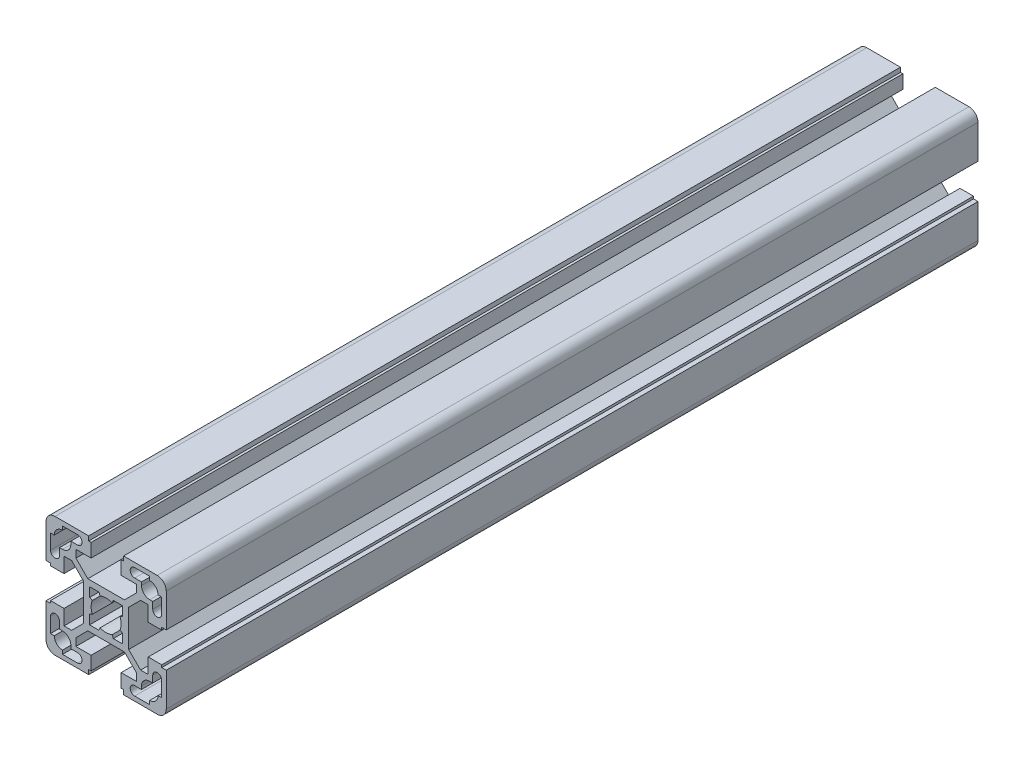
from build123d import *

# Parameters (mm, degrees)
EXTRUDE1_DEPTH = 270


with BuildPart() as part:
    # Sketch1 → Extrude1 (new body)
    with BuildSketch(Plane.XY):
        with BuildLine():
            Line((5.8, -20), (17, -20))
            ThreePointArc((17, -20), (19.121320344, -19.121320344), (20, -17))
            Line((20, -17), (20, -5.8))
            Line((20, -5.8), (18.5, -5.8))
            Line((18.5, -5.8), (18.5, -5))
            Line((18.5, -5), (14, -5))
            Line((14, -5), (14, -10.05))
            Line((14, -10.05), (11.464213562, -10.05))
            Line((11.464213562, -10.05), (7.5, -6.085786438))
            Line((7.5, -6.085786438), (7.5, 6.085786438))
            Line((7.5, 6.085786438), (11.464213562, 10.05))
            Line((11.464213562, 10.05), (14, 10.05))
            Line((14, 10.05), (14, 5))
            Line((14, 5), (18.5, 5))
            Line((18.5, 5), (18.5, 5.8))
            Line((18.5, 5.8), (20, 5.8))
            Line((20, 5.8), (20, 17))
            ThreePointArc((20, 17), (19.121320344, 19.121320344), (17, 20))
            Line((17, 20), (5.8, 20))
            Line((5.8, 20), (5.8, 18.5))
            Line((5.8, 18.5), (5, 18.5))
            Line((5, 18.5), (5, 14))
            Line((5, 14), (10.05, 14))
            Line((10.05, 14), (10.05, 11.464213562))
            Line((10.05, 11.464213562), (6.085786438, 7.5))
            Line((6.085786438, 7.5), (-6.085786438, 7.5))
            Line((-6.085786438, 7.5), (-10.05, 11.464213562))
            Line((-10.05, 11.464213562), (-10.05, 14))
            Line((-10.05, 14), (-5, 14))
            Line((-5, 14), (-5, 18.5))
            Line((-5, 18.5), (-5.8, 18.5))
            Line((-5.8, 18.5), (-5.8, 20))
            Line((-5.8, 20), (-17, 20))
            ThreePointArc((-17, 20), (-19.121320344, 19.121320344), (-20, 17))
            Line((-20, 17), (-20, 5.8))
            Line((-20, 5.8), (-18.5, 5.8))
            Line((-18.5, 5.8), (-18.5, 5))
            Line((-18.5, 5), (-14, 5))
            Line((-14, 5), (-14, 10.05))
            Line((-14, 10.05), (-11.464213562, 10.05))
            Line((-11.464213562, 10.05), (-7.5, 6.085786438))
            Line((-7.5, 6.085786438), (-7.5, -6.085786438))
            Line((-7.5, -6.085786438), (-11.464213562, -10.05))
            Line((-11.464213562, -10.05), (-14, -10.05))
            Line((-14, -10.05), (-14, -5))
            Line((-14, -5), (-18.5, -5))
            Line((-18.5, -5), (-18.5, -5.8))
            Line((-18.5, -5.8), (-20, -5.8))
            Line((-20, -5.8), (-20, -17))
            ThreePointArc((-20, -17), (-19.121320344, -19.121320344), (-17, -20))
            Line((-17, -20), (-5.8, -20))
            Line((-5.8, -20), (-5.8, -18.5))
            Line((-5.8, -18.5), (-5, -18.5))
            Line((-5, -18.5), (-5, -14))
            Line((-5, -14), (-10.05, -14))
            Line((-10.05, -14), (-10.05, -11.464213562))
            Line((-10.05, -11.464213562), (-6.085786438, -7.5))
            Line((-6.085786438, -7.5), (6.085786438, -7.5))
            Line((6.085786438, -7.5), (10.05, -11.464213562))
            Line((10.05, -11.464213562), (10.05, -14))
            Line((10.05, -14), (5, -14))
            Line((5, -14), (5, -18.5))
            Line((5, -18.5), (5.8, -18.5))
            Line((5.8, -18.5), (5.8, -20))
        make_face()
        with BuildLine():
            Line((14.5, -18.5), (9.5, -18.5))
            ThreePointArc((9.5, -18.5), (8, -17), (9.5, -15.5))
            Line((9.5, -15.5), (11.75, -15.5))
            Line((11.75, -15.5), (11.75, -14.5))
            ThreePointArc((11.75, -14.5), (12.555456352, -12.555456352), (14.5, -11.75))
            Line((14.5, -11.75), (15.5, -11.75))
            Line((15.5, -11.75), (15.5, -9.5))
            ThreePointArc((15.5, -9.5), (17, -8), (18.5, -9.5))
            Line((18.5, -9.5), (18.5, -14.5))
            Line((18.5, -14.5), (17.25, -14.5))
            ThreePointArc((17.25, -14.5), (16.444543648, -16.444543648), (14.5, -17.25))
            Line((14.5, -17.25), (14.5, -18.5))
        make_face(mode=Mode.SUBTRACT)
        with BuildLine():
            Line((18.5, 14.5), (17.25, 14.5))
            ThreePointArc((17.25, 14.5), (16.444543648, 16.444543648), (14.5, 17.25))
            Line((14.5, 17.25), (14.5, 18.5))
            Line((14.5, 18.5), (9.5, 18.5))
            ThreePointArc((9.5, 18.5), (8, 17), (9.5, 15.5))
            Line((9.5, 15.5), (11.75, 15.5))
            Line((11.75, 15.5), (11.75, 14.5))
            ThreePointArc((11.75, 14.5), (12.555456352, 12.555456352), (14.5, 11.75))
            Line((14.5, 11.75), (15.5, 11.75))
            Line((15.5, 11.75), (15.5, 9.5))
            ThreePointArc((15.5, 9.5), (17, 8), (18.5, 9.5))
            Line((18.5, 9.5), (18.5, 14.5))
        make_face(mode=Mode.SUBTRACT)
        with BuildLine():
            Line((5.5, 5.5), (2.397915762, 5.5))
            Line((2.397915762, 5.5), (1.998263135, 4.583333333))
            ThreePointArc((1.998263135, 4.583333333), (0, 5), (-1.998263135, 4.583333333))
            Line((-1.998263135, 4.583333333), (-2.397915762, 5.5))
            Line((-2.397915762, 5.5), (-5.5, 5.5))
            Line((-5.5, 5.5), (-5.5, 2.397915762))
            Line((-5.5, 2.397915762), (-4.583333333, 1.998263135))
            ThreePointArc((-4.583333333, 1.998263135), (-5, 0), (-4.583333333, -1.998263135))
            Line((-4.583333333, -1.998263135), (-5.5, -2.397915762))
            Line((-5.5, -2.397915762), (-5.5, -5.5))
            Line((-5.5, -5.5), (-2.397915762, -5.5))
            Line((-2.397915762, -5.5), (-1.998263135, -4.583333333))
            ThreePointArc((-1.998263135, -4.583333333), (0, -5), (1.998263135, -4.583333333))
            Line((1.998263135, -4.583333333), (2.397915762, -5.5))
            Line((2.397915762, -5.5), (5.5, -5.5))
            Line((5.5, -5.5), (5.5, -2.397915762))
            Line((5.5, -2.397915762), (4.583333333, -1.998263135))
            ThreePointArc((4.583333333, -1.998263135), (5, 0), (4.583333333, 1.998263135))
            Line((4.583333333, 1.998263135), (5.5, 2.397915762))
            Line((5.5, 2.397915762), (5.5, 5.5))
        make_face(mode=Mode.SUBTRACT)
        with BuildLine():
            Line((-18.5, -14.5), (-17.25, -14.5))
            ThreePointArc((-17.25, -14.5), (-16.444543648, -16.444543648), (-14.5, -17.25))
            Line((-14.5, -17.25), (-14.5, -18.5))
            Line((-14.5, -18.5), (-9.5, -18.5))
            ThreePointArc((-9.5, -18.5), (-8, -17), (-9.5, -15.5))
            Line((-9.5, -15.5), (-11.75, -15.5))
            Line((-11.75, -15.5), (-11.75, -14.5))
            ThreePointArc((-11.75, -14.5), (-12.555456352, -12.555456352), (-14.5, -11.75))
            Line((-14.5, -11.75), (-15.5, -11.75))
            Line((-15.5, -11.75), (-15.5, -9.5))
            ThreePointArc((-15.5, -9.5), (-17, -8), (-18.5, -9.5))
            Line((-18.5, -9.5), (-18.5, -14.5))
        make_face(mode=Mode.SUBTRACT)
        with BuildLine():
            Line((-14.5, 18.5), (-9.5, 18.5))
            ThreePointArc((-9.5, 18.5), (-8, 17), (-9.5, 15.5))
            Line((-9.5, 15.5), (-11.75, 15.5))
            Line((-11.75, 15.5), (-11.75, 14.5))
            ThreePointArc((-11.75, 14.5), (-12.555456352, 12.555456352), (-14.5, 11.75))
            Line((-14.5, 11.75), (-15.5, 11.75))
            Line((-15.5, 11.75), (-15.5, 9.5))
            ThreePointArc((-15.5, 9.5), (-17, 8), (-18.5, 9.5))
            Line((-18.5, 9.5), (-18.5, 14.5))
            Line((-18.5, 14.5), (-17.25, 14.5))
            ThreePointArc((-17.25, 14.5), (-16.444543648, 16.444543648), (-14.5, 17.25))
            Line((-14.5, 17.25), (-14.5, 18.5))
        make_face(mode=Mode.SUBTRACT)
    extrude(amount=EXTRUDE1_DEPTH)


solid = part.part
